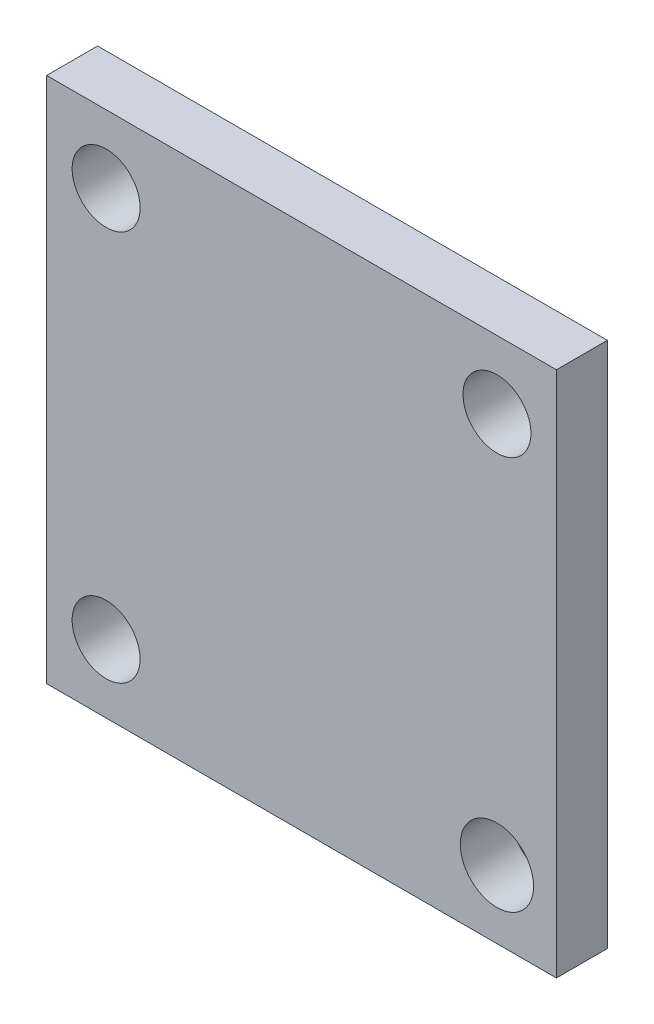
from build123d import *

# Parameters (mm, degrees)
SKETCH2_W           = 30.002183488
SKETCH2_H           = 31.002183488
SKETCH2_R           = 2
SKETCH2_R_2         = 2.156266898
BOSS_EXTRUDE1_DEPTH = 3


with BuildPart() as part:
    # Sketch2 → Boss-Extrude1 (new body)
    with BuildSketch(Plane.XY):
        Rectangle(SKETCH2_W, SKETCH2_H)
        with Locations((-11.498908256, 11.503275233)):
            Circle(SKETCH2_R, mode=Mode.SUBTRACT)
        with Locations((11.503275233, 11.501091744)):
            Circle(SKETCH2_R, mode=Mode.SUBTRACT)
        with Locations((-11.501091744, -11.498908256)):
            Circle(SKETCH2_R, mode=Mode.SUBTRACT)
        with Locations((11.501091744, -11.501091744)):
            Circle(SKETCH2_R_2, mode=Mode.SUBTRACT)
    extrude(amount=BOSS_EXTRUDE1_DEPTH)


solid = part.part
